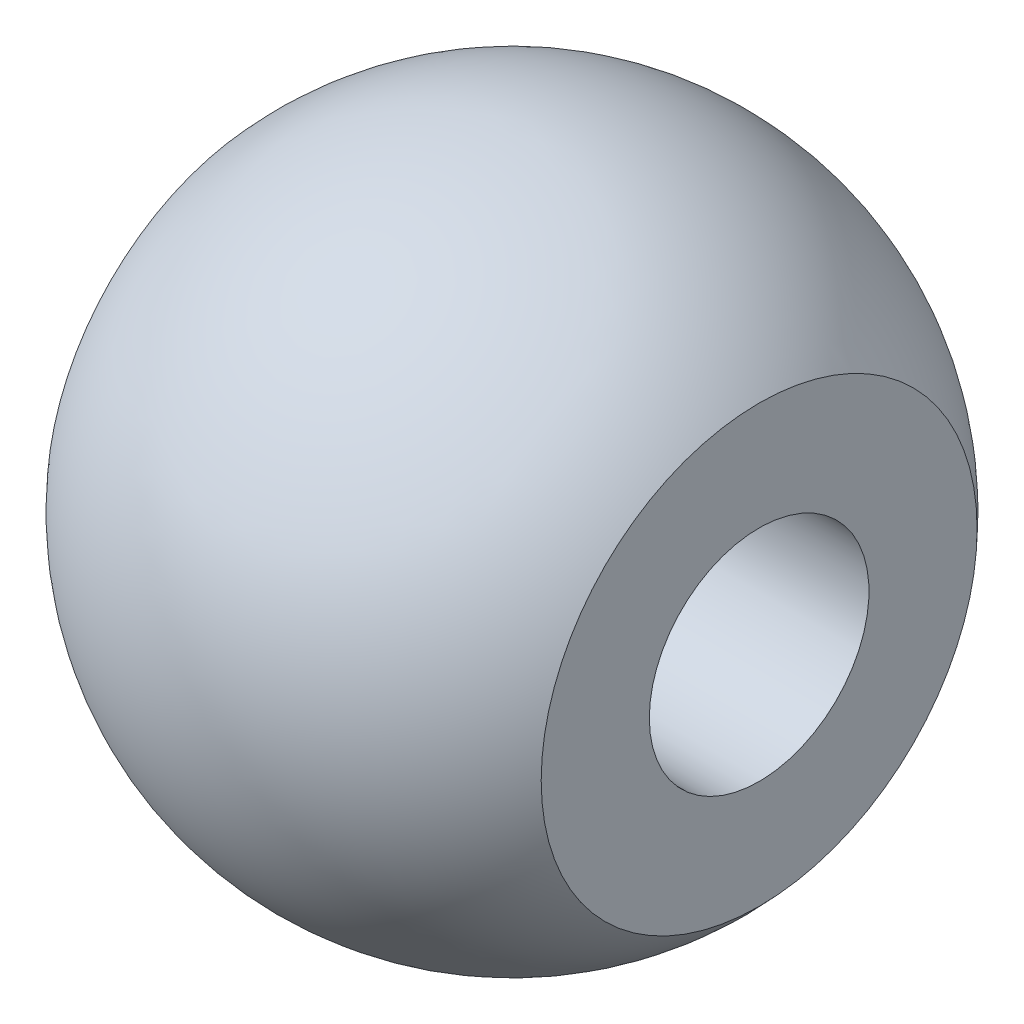
from build123d import *


with BuildPart() as part:
    # Sketch1 → Revolve1 (revolve)
    with BuildSketch(Plane.XY):
        with BuildLine():
            Line((-4.5, 0), (4.5, 0))
            Line((4.5, 0), (4.5, -3.968626967))
            ThreePointArc((4.5, -3.968626967), (0, -6), (-4.5, -3.968626967))
            Line((-4.5, -3.968626967), (-4.5, 0))
        make_face()
    revolve(axis=Axis((-4.5, 0, 0), (1, 0, 0)))

    # Sketch2 → Cut-Revolve1 (revolve, cut)
    with BuildSketch(Plane(origin=(0, 0, 0), x_dir=(1, 0, 0), z_dir=(0, 1, 0))):
        Polygon((-3.5, 2), (4.5, 2), (4.5, 0), (-4.5, 0), (-4.5, 3), align=None)
    revolve(axis=Axis((-4.5, 0, 0), (1, 0, 0)), mode=Mode.SUBTRACT)


solid = part.part
